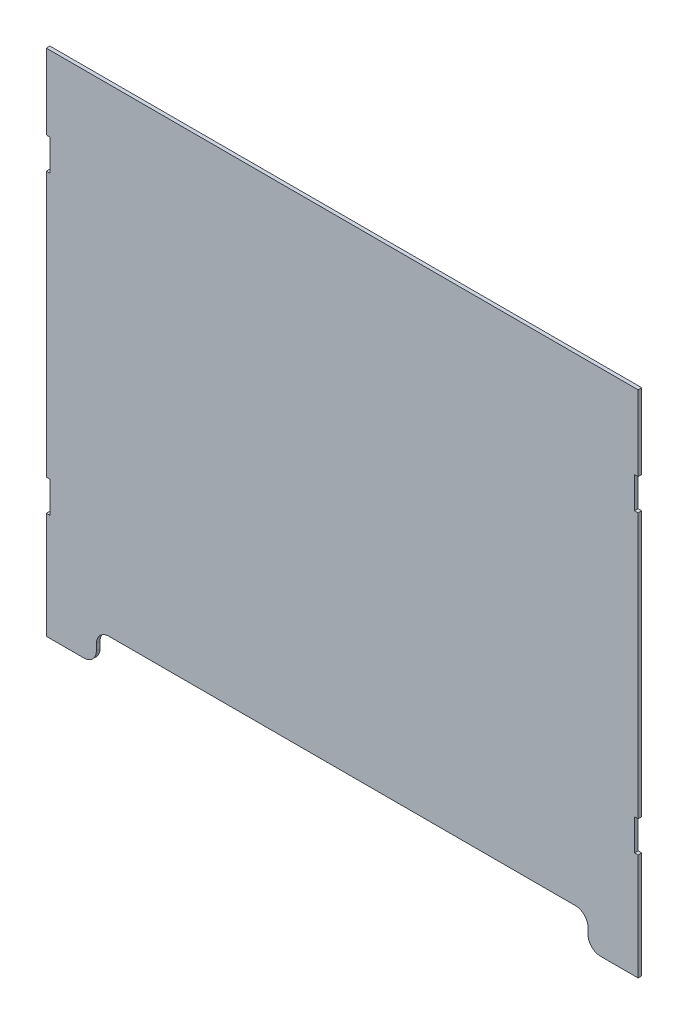
from build123d import *

# Parameters (mm, degrees)
BOSS_EXTRUDE1_DEPTH = 2.9


with BuildPart() as part:
    # Sketch1 → Boss-Extrude1 (new body)
    with BuildSketch(Plane.XY):
        with BuildLine():
            Line((206.1, -203.2), (236.1, -203.2))
            Line((236.1, -203.2), (236.1, -118.2))
            Line((236.1, -118.2), (233.2, -118.2))
            Line((233.2, -118.2), (233.2, -93.2))
            Line((233.2, -93.2), (236.1, -93.2))
            Line((236.1, -93.2), (236.1, 118.2))
            Line((236.1, 118.2), (233.2, 118.2))
            Line((233.2, 118.2), (233.2, 143.2))
            Line((233.2, 143.2), (236.1, 143.2))
            Line((236.1, 143.2), (236.1, 203.2))
            Line((236.1, 203.2), (-236.1, 203.2))
            Line((-236.1, 203.2), (-236.1, 143.2))
            Line((-236.1, 143.2), (-233.2, 143.2))
            Line((-233.2, 143.2), (-233.2, 118.2))
            Line((-233.2, 118.2), (-236.1, 118.2))
            Line((-236.1, 118.2), (-236.1, -93.2))
            Line((-236.1, -93.2), (-233.2, -93.2))
            Line((-233.2, -93.2), (-233.2, -118.2))
            Line((-233.2, -118.2), (-236.1, -118.2))
            Line((-236.1, -118.2), (-236.1, -203.2))
            Line((-236.1, -203.2), (-206.1, -203.2))
            ThreePointArc((-206.1, -203.2), (-199.028932188, -200.271067812), (-196.1, -193.2))
            Line((-196.1, -193.2), (-196.1, -188.2))
            ThreePointArc((-196.1, -188.2), (-193.171067812, -181.128932188), (-186.1, -178.2))
            Line((-186.1, -178.2), (186.1, -178.2))
            ThreePointArc((186.1, -178.2), (193.171067812, -181.128932188), (196.1, -188.2))
            Line((196.1, -188.2), (196.1, -193.2))
            ThreePointArc((196.1, -193.2), (199.028932188, -200.271067812), (206.1, -203.2))
        make_face()
    extrude(amount=BOSS_EXTRUDE1_DEPTH)


solid = part.part
